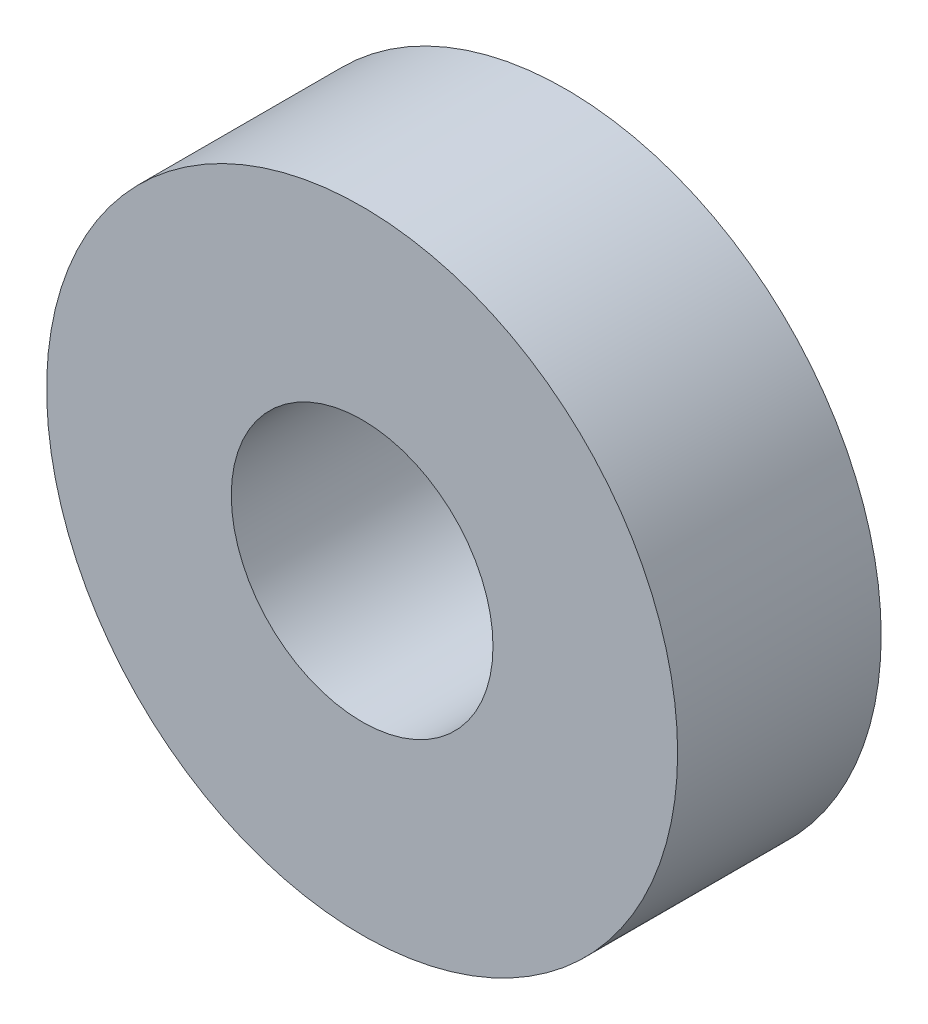
from build123d import *

# Parameters (mm, degrees)
SKETCH2_R           = 10.85
SKETCH2_R_2         = 1.75
SKETCH2_R_3         = 4.5
BOSS_EXTRUDE1_DEPTH = 7
SKETCH3_R           = 1.75
BOSS_EXTRUDE2_DEPTH = 3


with BuildPart() as part:
    # Sketch2 → Boss-Extrude1 (new body)
    with BuildSketch(Plane.XY.offset(-31.892451267)):
        Circle(SKETCH2_R)
        with Locations((-7.6, 0)):
            Circle(SKETCH2_R_2, mode=Mode.SUBTRACT)
        with Locations((7.6, 0)):
            Circle(SKETCH2_R_2, mode=Mode.SUBTRACT)
        Circle(SKETCH2_R_3, mode=Mode.SUBTRACT)
        with Locations((0, 7.6)):
            Circle(SKETCH2_R_2, mode=Mode.SUBTRACT)
        with Locations((0, -7.6)):
            Circle(SKETCH2_R_2, mode=Mode.SUBTRACT)
    extrude(amount=BOSS_EXTRUDE1_DEPTH)

    # Sketch3 → Boss-Extrude2 (add)
    with BuildSketch(Plane.XY.offset(-24.892451267)):
        with Locations((0, 7.6)):
            Circle(SKETCH3_R)
        with Locations((-7.6, 0)):
            Circle(SKETCH3_R)
        with Locations((0, -7.6)):
            Circle(SKETCH3_R)
        with Locations((7.6, 0)):
            Circle(SKETCH3_R)
    extrude(amount=-BOSS_EXTRUDE2_DEPTH)


solid = part.part
